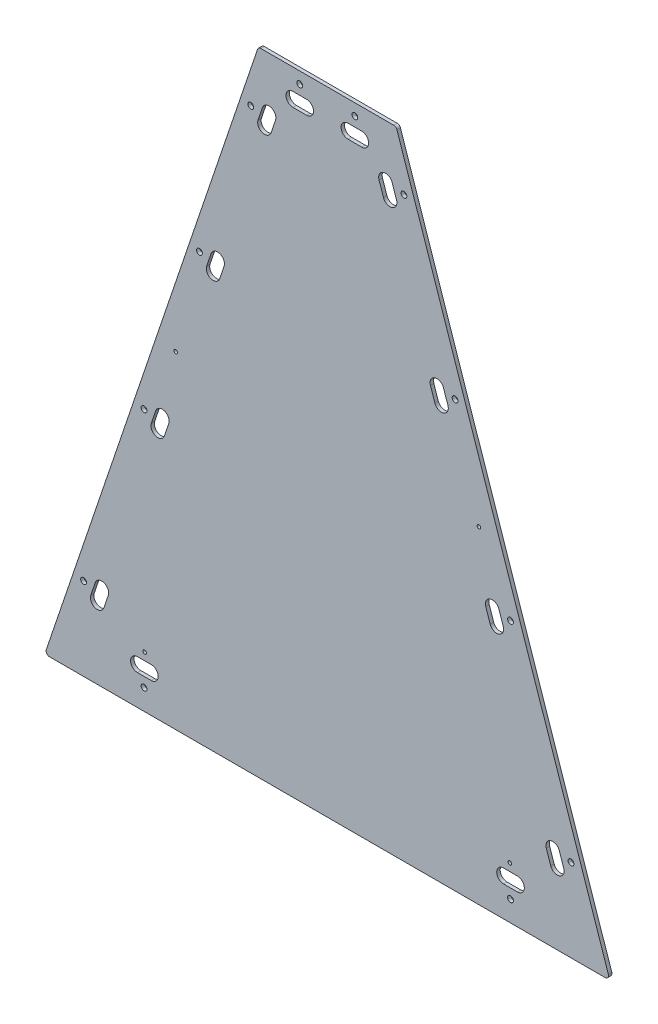
from build123d import *

# Parameters (mm, degrees)
SKETCH1_R                        = 5.3578125
BOSS_EXTRUDE1_DEPTH              = 6.35
FILLET1_R                        = 6.35
F_17_64_0_26563_DIAMETER_HOLE1_D = 6.747002


with BuildPart() as part:
    # Sketch1 → Boss-Extrude1 (new body)
    with BuildSketch(Plane.XY):
        Polygon((128.546632935, 292.971606529), (382.546632935, 292.971606529), (776.246632935, -872.634633965), (-265.153367065, -872.634633965), align=None)
        with Locations((396.756156044, 191.371606529)):
            Circle(SKETCH1_R, mode=Mode.SUBTRACT)
        with Locations((114.659199441, 192.325199783)):
            Circle(SKETCH1_R, mode=Mode.SUBTRACT)
        with Locations((-193.570796303, -720.234633965)):
            Circle(SKETCH1_R, mode=Mode.SUBTRACT)
        with Locations((704.664062174, -720.234633965)):
            Circle(SKETCH1_R, mode=Mode.SUBTRACT)
        with Locations((491.127459301, -88.028393471)):
            Circle(SKETCH1_R, mode=Mode.SUBTRACT)
        with Locations((593.220051006, -390.288393471)):
            Circle(SKETCH1_R, mode=Mode.SUBTRACT)
        with Locations((19.96580657, -88.028393471)):
            Circle(SKETCH1_R, mode=Mode.SUBTRACT)
        with Locations((-82.126785136, -390.288393471)):
            Circle(SKETCH1_R, mode=Mode.SUBTRACT)
        with Locations((306.346632935, 271.727158802)):
            Circle(SKETCH1_R, mode=Mode.SUBTRACT)
        with Locations((204.746632935, 271.727158802)):
            Circle(SKETCH1_R, mode=Mode.SUBTRACT)
        with Locations((-82.126785136, -834.534633965)):
            Circle(SKETCH1_R, mode=Mode.SUBTRACT)
        with Locations((593.220051006, -834.534633965)):
            Circle(SKETCH1_R, mode=Mode.SUBTRACT)
        with BuildLine():
            Line((-180.239726648, -736.327985402), (-172.111642745, -712.26360816))
            ThreePointArc((-172.111642745, -712.26360816), (-156.015412172, -704.29546149), (-148.047265502, -720.391692063))
            Line((-148.047265502, -720.391692063), (-156.175349405, -744.456069305))
            ThreePointArc((-156.175349405, -744.456069305), (-172.271579978, -752.424215975), (-180.239726648, -736.327985402))
        make_face(mode=Mode.SUBTRACT)
        with BuildLine():
            Line((-94.231734473, -791.354633965), (-68.831734473, -791.354633965))
            ThreePointArc((-68.831734473, -791.354633965), (-56.131734473, -804.054633965), (-68.831734473, -816.754633965))
            Line((-68.831734473, -816.754633965), (-94.231734473, -816.754633965))
            ThreePointArc((-94.231734473, -816.754633965), (-106.931734473, -804.054633965), (-94.231734473, -791.354633965))
        make_face(mode=Mode.SUBTRACT)
        with BuildLine():
            Line((580.520051006, -791.354633965), (605.920051006, -791.354633965))
            ThreePointArc((605.920051006, -791.354633965), (618.620051006, -804.054633965), (605.920051006, -816.754633965))
            Line((605.920051006, -816.754633965), (580.520051006, -816.754633965))
            ThreePointArc((580.520051006, -816.754633965), (567.820051006, -804.054633965), (580.520051006, -791.354633965))
        make_face(mode=Mode.SUBTRACT)
        with BuildLine():
            Line((-68.772097635, -406.311820835), (-60.644013732, -382.247443592))
            ThreePointArc((-60.644013732, -382.247443592), (-44.54778316, -374.279296923), (-36.57963649, -390.375527495))
            Line((-36.57963649, -390.375527495), (-44.707720392, -414.439904738))
            ThreePointArc((-44.707720392, -414.439904738), (-60.803950965, -422.408051408), (-68.772097635, -406.311820835))
        make_face(mode=Mode.SUBTRACT)
        with BuildLine():
            Line((33.202373314, -104.401534553), (41.330457217, -80.33715731))
            ThreePointArc((41.330457217, -80.33715731), (57.426687789, -72.36901064), (65.394834459, -88.465241213))
            Line((65.394834459, -88.465241213), (57.266750557, -112.529618456))
            ThreePointArc((57.266750557, -112.529618456), (41.170519984, -120.497765125), (33.202373314, -104.401534553))
        make_face(mode=Mode.SUBTRACT)
        with BuildLine():
            Line((127.949253412, 176.110415433), (136.077337315, 200.174792676))
            ThreePointArc((136.077337315, 200.174792676), (152.173567887, 208.142939345), (160.141714557, 192.046708773))
            Line((160.141714557, 192.046708773), (152.013630654, 167.98233153))
            ThreePointArc((152.013630654, 167.98233153), (135.917400082, 160.01418486), (127.949253412, 176.110415433))
        make_face(mode=Mode.SUBTRACT)
        with BuildLine():
            Line((192.113515822, 253.947158802), (217.513515822, 253.947158802))
            ThreePointArc((217.513515822, 253.947158802), (230.213515822, 241.247158802), (217.513515822, 228.547158802))
            Line((217.513515822, 228.547158802), (192.113515822, 228.547158802))
            ThreePointArc((192.113515822, 228.547158802), (179.413515822, 241.247158802), (192.113515822, 253.947158802))
        make_face(mode=Mode.SUBTRACT)
        with BuildLine():
            Line((293.646632935, 253.947158802), (319.046632935, 253.947158802))
            ThreePointArc((319.046632935, 253.947158802), (331.746632935, 241.247158802), (319.046632935, 228.547158802))
            Line((319.046632935, 228.547158802), (293.646632935, 228.547158802))
            ThreePointArc((293.646632935, 228.547158802), (280.946632935, 241.247158802), (293.646632935, 253.947158802))
        make_face(mode=Mode.SUBTRACT)
        with BuildLine():
            Line((359.065010443, 168.025630302), (350.936926541, 192.090007545))
            ThreePointArc((350.936926541, 192.090007545), (358.905073211, 208.186238118), (375.001303783, 200.218091448))
            Line((375.001303783, 200.218091448), (383.129387686, 176.153714205))
            ThreePointArc((383.129387686, 176.153714205), (375.161241016, 160.057483633), (359.065010443, 168.025630302))
        make_face(mode=Mode.SUBTRACT)
        with BuildLine():
            Line((453.826515314, -112.529618456), (445.698431411, -88.465241213))
            ThreePointArc((445.698431411, -88.465241213), (453.666578081, -72.36901064), (469.762808654, -80.33715731))
            Line((469.762808654, -80.33715731), (477.890892557, -104.401534553))
            ThreePointArc((477.890892557, -104.401534553), (469.922745887, -120.497765125), (453.826515314, -112.529618456))
        make_face(mode=Mode.SUBTRACT)
        with BuildLine():
            Line((555.800986263, -414.439904738), (547.67290236, -390.375527495))
            ThreePointArc((547.67290236, -390.375527495), (555.64104903, -374.279296923), (571.737279603, -382.247443592))
            Line((571.737279603, -382.247443592), (579.865363506, -406.311820835))
            ThreePointArc((579.865363506, -406.311820835), (571.897216836, -422.408051408), (555.800986263, -414.439904738))
        make_face(mode=Mode.SUBTRACT)
        with BuildLine():
            Line((667.268615276, -744.456069305), (659.140531373, -720.391692063))
            ThreePointArc((659.140531373, -720.391692063), (667.108678043, -704.29546149), (683.204908616, -712.26360816))
            Line((683.204908616, -712.26360816), (691.332992518, -736.327985402))
            ThreePointArc((691.332992518, -736.327985402), (683.364845848, -752.424215975), (667.268615276, -744.456069305))
        make_face(mode=Mode.SUBTRACT)
    extrude(amount=BOSS_EXTRUDE1_DEPTH)

    # Fillet1
    fillet1_edges = [part.edges().sort_by_distance(p)[0] for p in [
        (128.546632935, 292.971606529, 3.175),
        (382.546632935, 292.971606529, 3.175),
        (776.246632935, -872.634633965, 3.175),
        (-265.153367065, -872.634633965, 3.175),
    ]]
    fillet(fillet1_edges, radius=FILLET1_R)

    # 17/64 (0.26563) Diameter Hole1 (through all)
    with Locations(Plane.XY.offset(6.35)):
        with Locations((-23.853367065, -269.384633965), (534.946632935, -269.384633965), (592.096632935, -777.384633965), (-81.003367065, -777.384633965)):
            Hole(F_17_64_0_26563_DIAMETER_HOLE1_D / 2)


solid = part.part
